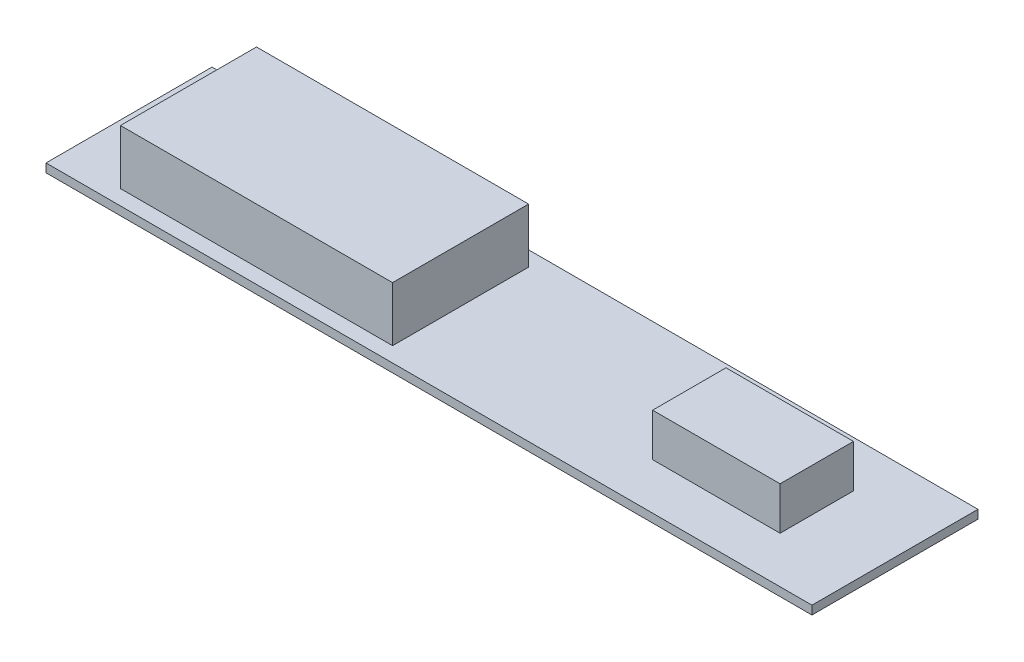
from build123d import *

# Parameters (mm, degrees)
SKETCH1_W           = 143
SKETCH1_H           = 31
BOSS_EXTRUDE1_DEPTH = 1.6
SKETCH2_W           = 23.8
SKETCH2_H           = 13.7
BOSS_EXTRUDE2_DEPTH = 8
SKETCH3_W           = 50.8
SKETCH3_H           = 25.4
BOSS_EXTRUDE3_DEPTH = 10.2


with BuildPart() as part:
    # Sketch1 → Boss-Extrude1 (new body)
    with BuildSketch(Plane(origin=(0, 0, 0), x_dir=(1, 0, 0), z_dir=(0, 1, 0))):
        Rectangle(SKETCH1_W, SKETCH1_H)
    extrude(amount=BOSS_EXTRUDE1_DEPTH)

    # Sketch2 → Boss-Extrude2 (add)
    with BuildSketch(Plane(origin=(0, 1.6, 0), x_dir=(1, 0, 0), z_dir=(0, 1, 0))):
        with Locations((45, 0)):
            Rectangle(SKETCH2_W, SKETCH2_H)
    extrude(amount=BOSS_EXTRUDE2_DEPTH)

    # Sketch3 → Boss-Extrude3 (add)
    with BuildSketch(Plane(origin=(0, 1.6, 0), x_dir=(1, 0, 0), z_dir=(0, 1, 0))):
        with Locations((-35, 0)):
            Rectangle(SKETCH3_W, SKETCH3_H)
    extrude(amount=BOSS_EXTRUDE3_DEPTH)


solid = part.part
